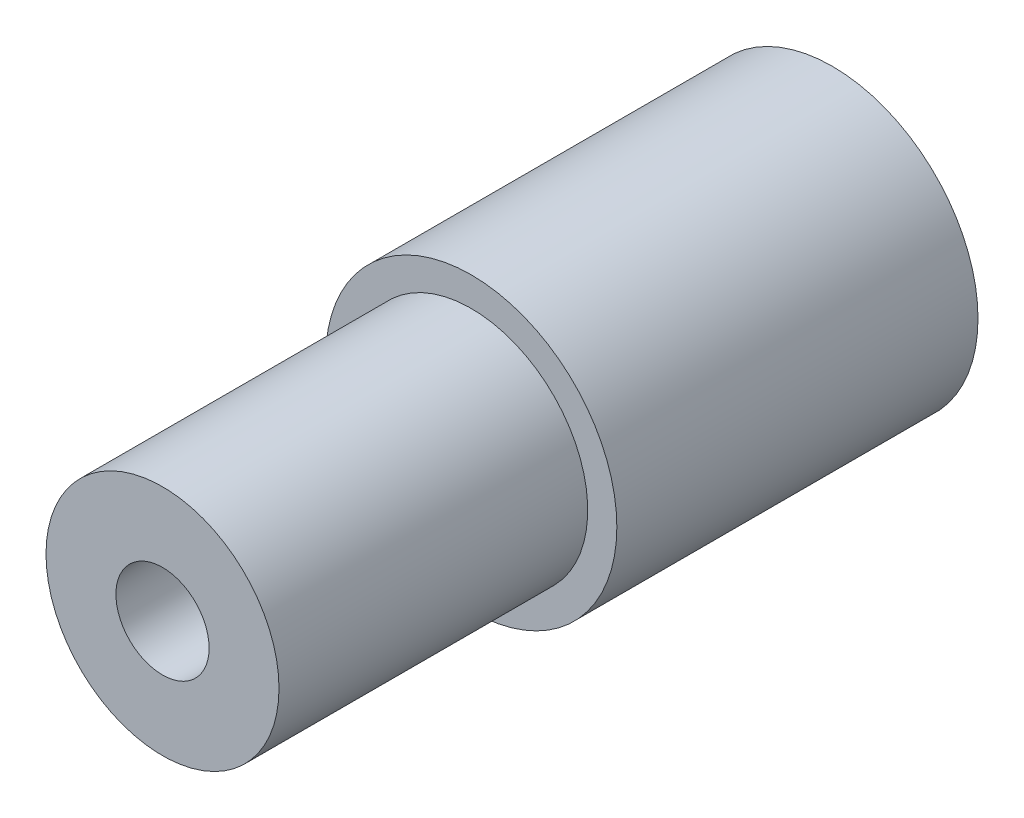
from build123d import *

# Parameters (mm, degrees)
SKETCH2_R           = 4
SKETCH2_R_2         = 1.6
BOSS_EXTRUDE1_DEPTH = 23
SKETCH3_R           = 5
SKETCH3_R_2         = 4
BOSS_EXTRUDE2_DEPTH = 12.4


with BuildPart() as part:
    # Sketch2 → Boss-Extrude1 (new body)
    with BuildSketch(Plane.XY):
        Circle(SKETCH2_R)
        Circle(SKETCH2_R_2, mode=Mode.SUBTRACT)
    extrude(amount=BOSS_EXTRUDE1_DEPTH)

    # Sketch3 → Boss-Extrude2 (add)
    with BuildSketch(Plane(origin=(0, 0, 0), x_dir=(-1, 0, 0), z_dir=(0, 0, -1))):
        Circle(SKETCH3_R)
        Circle(SKETCH3_R_2, mode=Mode.SUBTRACT)
    extrude(amount=-BOSS_EXTRUDE2_DEPTH)


solid = part.part
